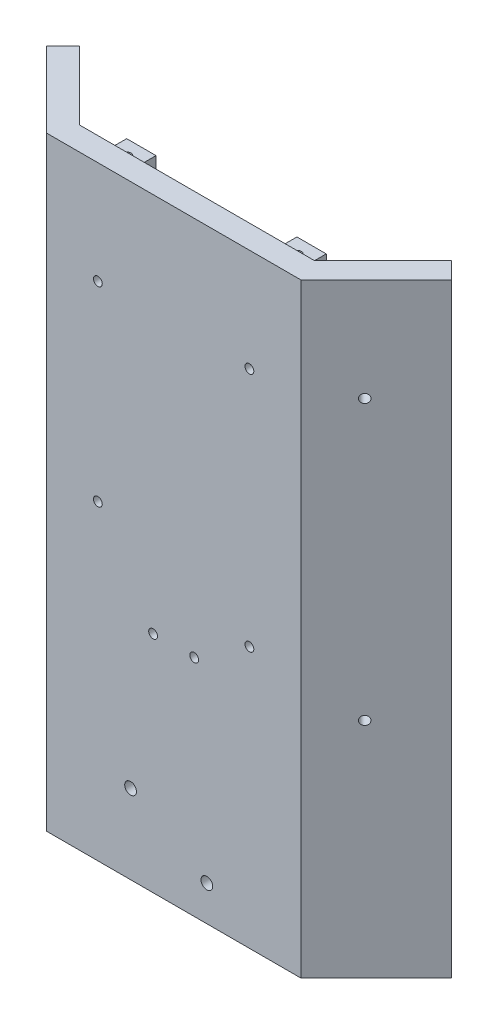
from build123d import *

# Parameters (mm, degrees)
BOSS_EXTRUDE1_DEPTH = 206
SKETCH2_W           = 10
SKETCH2_H           = 6
BOSS_EXTRUDE2_DEPTH = 10
CUT_EXTRUDE1_REACH  = 202
SKETCH3_R           = 1.5
CUT_EXTRUDE2_REACH  = 33.335
SKETCH4_R           = 2
CUT_EXTRUDE3_REACH  = 33.335
SKETCH5_R           = 1.5
CUT_EXTRUDE4_REACH  = 33.335
SKETCH6_R           = 1.5
CUT_EXTRUDE5_REACH  = 103.569
SKETCH7_R           = 1.5
CUT_EXTRUDE6_REACH  = 103.569
SKETCH8_R           = 1.5


with BuildPart() as part:
    # Sketch1 → Boss-Extrude1 (new body)
    with BuildSketch(Plane(origin=(0, 0, 0), x_dir=(1, 0, 0), z_dir=(0, 1, 0))):
        Polygon((-40, 0), (40, 0), (63.334523779, 23.334523779), (68.991378029, 17.67766953), (43.313708499, -8), (-43.313708499, -8), (-68.991378029, 17.67766953), (-63.334523779, 23.334523779), align=None)
    extrude(amount=BOSS_EXTRUDE1_DEPTH)

    # Sketch2 → Boss-Extrude2 (add)
    with BuildSketch(Plane(origin=(0, 0, 0), x_dir=(-1, 0, 0), z_dir=(0, 0, -1))):
        with Locations((-29, 197)):
            Rectangle(SKETCH2_W, SKETCH2_H)
        with Locations((29, 197)):
            Rectangle(SKETCH2_W, SKETCH2_H)
    extrude(amount=BOSS_EXTRUDE2_DEPTH)

    # Sketch3 → Cut-Extrude1 (cut, up to next)
    with BuildSketch(Plane(origin=(0, 200, 0), x_dir=(1, 0, 0), z_dir=(0, 1, 0)), mode=Mode.PRIVATE) as cut_extrude1_sk1:
        with Locations((-29, 5)):
            Circle(SKETCH3_R)
    cut_extrude1_tool1 = extrude(cut_extrude1_sk1.sketch, amount=-CUT_EXTRUDE1_REACH, mode=Mode.PRIVATE) & part.part
    add(cut_extrude1_tool1.solids().sort_by_distance((-29, 200, -5))[0], mode=Mode.SUBTRACT)
    # Sketch3 → Cut-Extrude1 (cut, up to next)
    with BuildSketch(Plane(origin=(0, 200, 0), x_dir=(1, 0, 0), z_dir=(0, 1, 0)), mode=Mode.PRIVATE) as cut_extrude1_sk2:
        with Locations((29, 5)):
            Circle(SKETCH3_R)
    cut_extrude1_tool2 = extrude(cut_extrude1_sk2.sketch, amount=-CUT_EXTRUDE1_REACH, mode=Mode.PRIVATE) & part.part
    add(cut_extrude1_tool2.solids().sort_by_distance((29, 200, -5))[0], mode=Mode.SUBTRACT)

    # Sketch4 → Cut-Extrude2 (cut, up to next)
    with BuildSketch(Plane.XY.offset(8), mode=Mode.PRIVATE) as cut_extrude2_sk1:
        with Locations((-14.667053615, 27)):
            Circle(SKETCH4_R)
    cut_extrude2_tool1 = extrude(cut_extrude2_sk1.sketch, amount=-CUT_EXTRUDE2_REACH, mode=Mode.PRIVATE) & part.part
    add(cut_extrude2_tool1.solids().sort_by_distance((-14.667054, 27, 8))[0], mode=Mode.SUBTRACT)
    # Sketch4 → Cut-Extrude2 (cut, up to next)
    with BuildSketch(Plane.XY.offset(8), mode=Mode.PRIVATE) as cut_extrude2_sk2:
        with Locations((11.313708499, 12)):
            Circle(SKETCH4_R)
    cut_extrude2_tool2 = extrude(cut_extrude2_sk2.sketch, amount=-CUT_EXTRUDE2_REACH, mode=Mode.PRIVATE) & part.part
    add(cut_extrude2_tool2.solids().sort_by_distance((11.313708, 12, 8))[0], mode=Mode.SUBTRACT)

    # Sketch5 → Cut-Extrude3 (cut, up to next)
    with BuildSketch(Plane.XY.offset(8), mode=Mode.PRIVATE) as cut_extrude3_sk1:
        with Locations((-7, 76.404082058)):
            Circle(SKETCH5_R)
    cut_extrude3_tool1 = extrude(cut_extrude3_sk1.sketch, amount=-CUT_EXTRUDE3_REACH, mode=Mode.PRIVATE) & part.part
    add(cut_extrude3_tool1.solids().sort_by_distance((-7, 76.404082, 8))[0], mode=Mode.SUBTRACT)
    # Sketch5 → Cut-Extrude3 (cut, up to next)
    with BuildSketch(Plane.XY.offset(8), mode=Mode.PRIVATE) as cut_extrude3_sk2:
        with Locations((7, 76.404082058)):
            Circle(SKETCH5_R)
    cut_extrude3_tool2 = extrude(cut_extrude3_sk2.sketch, amount=-CUT_EXTRUDE3_REACH, mode=Mode.PRIVATE) & part.part
    add(cut_extrude3_tool2.solids().sort_by_distance((7, 76.404082, 8))[0], mode=Mode.SUBTRACT)

    # Sketch6 → Cut-Extrude4 (cut, up to next)
    with BuildSketch(Plane.XY.offset(8), mode=Mode.PRIVATE) as cut_extrude4_sk1:
        with Locations((-25.813708499, 171)):
            Circle(SKETCH6_R)
    cut_extrude4_tool1 = extrude(cut_extrude4_sk1.sketch, amount=-CUT_EXTRUDE4_REACH, mode=Mode.PRIVATE) & part.part
    add(cut_extrude4_tool1.solids().sort_by_distance((-25.813708, 171, 8))[0], mode=Mode.SUBTRACT)
    # Sketch6 → Cut-Extrude4 (cut, up to next)
    with BuildSketch(Plane.XY.offset(8), mode=Mode.PRIVATE) as cut_extrude4_sk2:
        with Locations((25.813708499, 171)):
            Circle(SKETCH6_R)
    cut_extrude4_tool2 = extrude(cut_extrude4_sk2.sketch, amount=-CUT_EXTRUDE4_REACH, mode=Mode.PRIVATE) & part.part
    add(cut_extrude4_tool2.solids().sort_by_distance((25.813708, 171, 8))[0], mode=Mode.SUBTRACT)
    # Sketch6 → Cut-Extrude4 (cut, up to next)
    with BuildSketch(Plane.XY.offset(8), mode=Mode.PRIVATE) as cut_extrude4_sk3:
        with Locations((-25.813708499, 106)):
            Circle(SKETCH6_R)
    cut_extrude4_tool3 = extrude(cut_extrude4_sk3.sketch, amount=-CUT_EXTRUDE4_REACH, mode=Mode.PRIVATE) & part.part
    add(cut_extrude4_tool3.solids().sort_by_distance((-25.813708, 106, 8))[0], mode=Mode.SUBTRACT)
    # Sketch6 → Cut-Extrude4 (cut, up to next)
    with BuildSketch(Plane.XY.offset(8), mode=Mode.PRIVATE) as cut_extrude4_sk4:
        with Locations((25.813708499, 89)):
            Circle(SKETCH6_R)
    cut_extrude4_tool4 = extrude(cut_extrude4_sk4.sketch, amount=-CUT_EXTRUDE4_REACH, mode=Mode.PRIVATE) & part.part
    add(cut_extrude4_tool4.solids().sort_by_distance((25.813708, 89, 8))[0], mode=Mode.SUBTRACT)

    # Sketch7 → Cut-Extrude5 (cut, up to next)
    with BuildSketch(Plane(origin=(-25.656854249, 0, 25.656854249), x_dir=(0.707106781, 0, 0.707106781), z_dir=(-0.707106781, 0, 0.707106781)), mode=Mode.PRIVATE) as cut_extrude5_sk1:
        with Locations((-43.414271247, 171)):
            Circle(SKETCH7_R)
    cut_extrude5_tool1 = extrude(cut_extrude5_sk1.sketch, amount=-CUT_EXTRUDE5_REACH, mode=Mode.PRIVATE) & part.part
    add(cut_extrude5_tool1.solids().sort_by_distance((-56.35538, 171, -5.041671))[0], mode=Mode.SUBTRACT)
    # Sketch7 → Cut-Extrude5 (cut, up to next)
    with BuildSketch(Plane(origin=(-25.656854249, 0, 25.656854249), x_dir=(0.707106781, 0, 0.707106781), z_dir=(-0.707106781, 0, 0.707106781)), mode=Mode.PRIVATE) as cut_extrude5_sk2:
        with Locations((-43.414271247, 81)):
            Circle(SKETCH7_R)
    cut_extrude5_tool2 = extrude(cut_extrude5_sk2.sketch, amount=-CUT_EXTRUDE5_REACH, mode=Mode.PRIVATE) & part.part
    add(cut_extrude5_tool2.solids().sort_by_distance((-56.35538, 81, -5.041671))[0], mode=Mode.SUBTRACT)

    # Sketch8 → Cut-Extrude6 (cut, up to next)
    with BuildSketch(Plane(origin=(25.656854249, 0, 25.656854249), x_dir=(0.707106781, 0, -0.707106781), z_dir=(0.707106781, 0, 0.707106781)), mode=Mode.PRIVATE) as cut_extrude6_sk1:
        with Locations((40.384271247, 171)):
            Circle(SKETCH8_R)
    cut_extrude6_tool1 = extrude(cut_extrude6_sk1.sketch, amount=-CUT_EXTRUDE6_REACH, mode=Mode.PRIVATE) & part.part
    add(cut_extrude6_tool1.solids().sort_by_distance((54.212846, 171, -2.899138))[0], mode=Mode.SUBTRACT)
    # Sketch8 → Cut-Extrude6 (cut, up to next)
    with BuildSketch(Plane(origin=(25.656854249, 0, 25.656854249), x_dir=(0.707106781, 0, -0.707106781), z_dir=(0.707106781, 0, 0.707106781)), mode=Mode.PRIVATE) as cut_extrude6_sk2:
        with Locations((40.384271247, 76)):
            Circle(SKETCH8_R)
    cut_extrude6_tool2 = extrude(cut_extrude6_sk2.sketch, amount=-CUT_EXTRUDE6_REACH, mode=Mode.PRIVATE) & part.part
    add(cut_extrude6_tool2.solids().sort_by_distance((54.212846, 76, -2.899138))[0], mode=Mode.SUBTRACT)


solid = part.part
